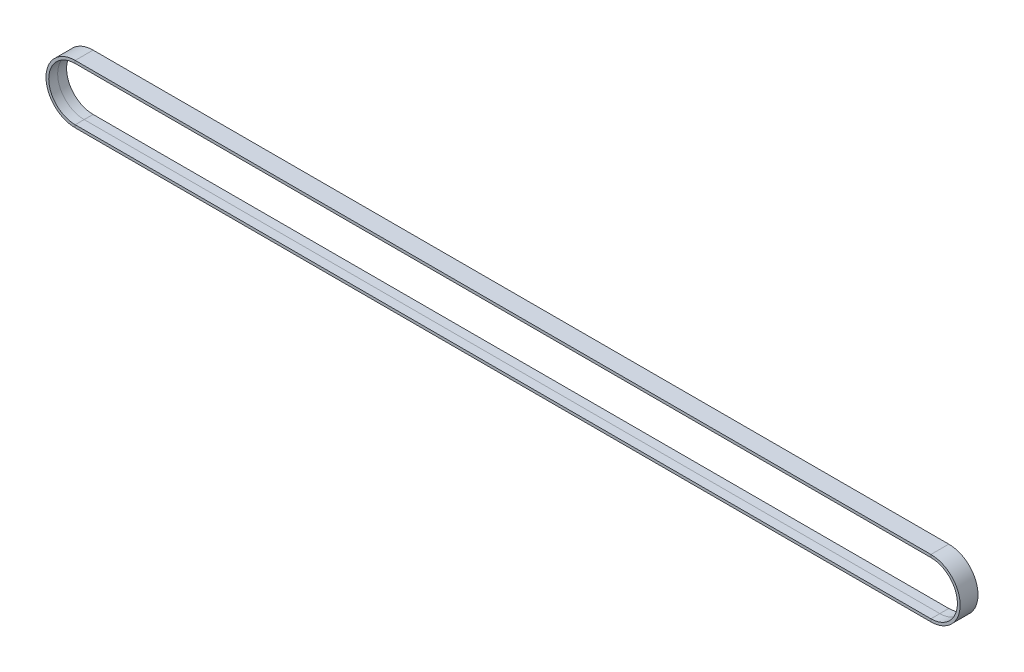
from build123d import *


with BuildPart() as part:
    # ｽｲｰﾌﾟ1: sweep along a path in ｽｹｯﾁ2
    with BuildLine(Plane.XY) as sweep_1_path:
        Line((0, -13.345), (-431, -13.345))
        ThreePointArc((-431, -13.345), (-444.345, 0), (-431, 13.345))
        Line((-431, 13.345), (0, 13.345))
        ThreePointArc((0, 13.345), (13.345, 0), (0, -13.345))
    # Sketch 3D_3 → ｽｲｰﾌﾟ1 (sweep)
    with BuildSketch(Plane(origin=(0, 13.345, 0), x_dir=(-1.3735006890805393e-13, 0.29124620867342393, -0.956648130679905), z_dir=(1, 0, 0))):
        Polygon((0, 0), (4.304916588, -1.310607939), (4.703923894, 0), (-3.905909282, 2.621215878), (-4.304916588, 1.310607939), align=None)
    sweep(path=sweep_1_path.line)


solid = part.part
